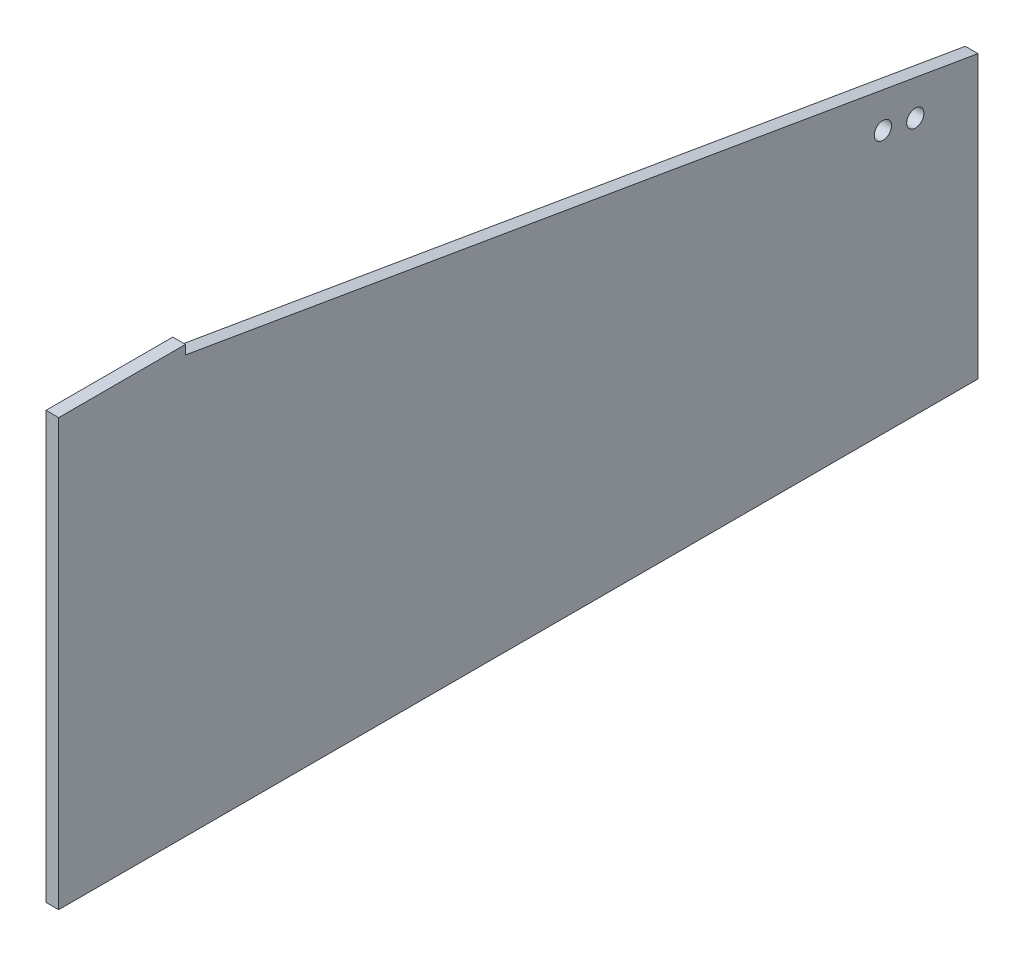
from build123d import *

# Parameters (mm, degrees)
SKETCH1_R           = 12.25
BOSS_EXTRUDE1_DEPTH = 18


with BuildPart() as part:
    # Sketch1 → Boss-Extrude1 (new body)
    with BuildSketch(Plane(origin=(0, 0, 0), x_dir=(0, 0, -1), z_dir=(1, 0, 0))):
        Polygon((0, 0), (0, 605), (180, 605), (180, 592), (1305, 400), (1305, 0), align=None)
        with Locations((1216, 365.189333333)):
            Circle(SKETCH1_R, mode=Mode.SUBTRACT)
        with Locations((1170, 373.04)):
            Circle(SKETCH1_R, mode=Mode.SUBTRACT)
    extrude(amount=BOSS_EXTRUDE1_DEPTH)


solid = part.part
